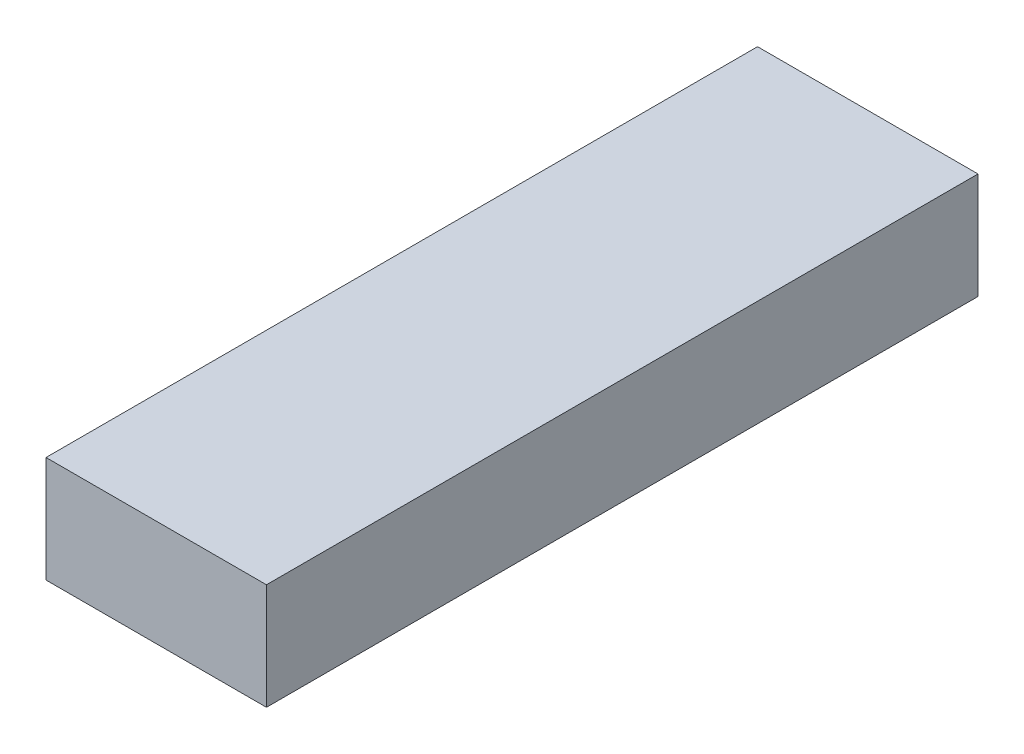
from build123d import *

# Parameters (mm, degrees)
BOSS_EXTRUDE1_DEPTH      = 77.47
BOSS_EXTRUDE1_DEPTH_BACK = 77.47
SKETCH1_W                = 48.006
SKETCH1_H                = 23.114


with BuildPart() as part:
    # Sketch1 → Boss-Extrude1 (new, two sides: drawn at the far end of the back side and taken through both)
    with BuildSketch(Plane.XY.offset(-BOSS_EXTRUDE1_DEPTH_BACK)):
        Rectangle(SKETCH1_W, SKETCH1_H)
    extrude(amount=BOSS_EXTRUDE1_DEPTH + BOSS_EXTRUDE1_DEPTH_BACK)


solid = part.part
